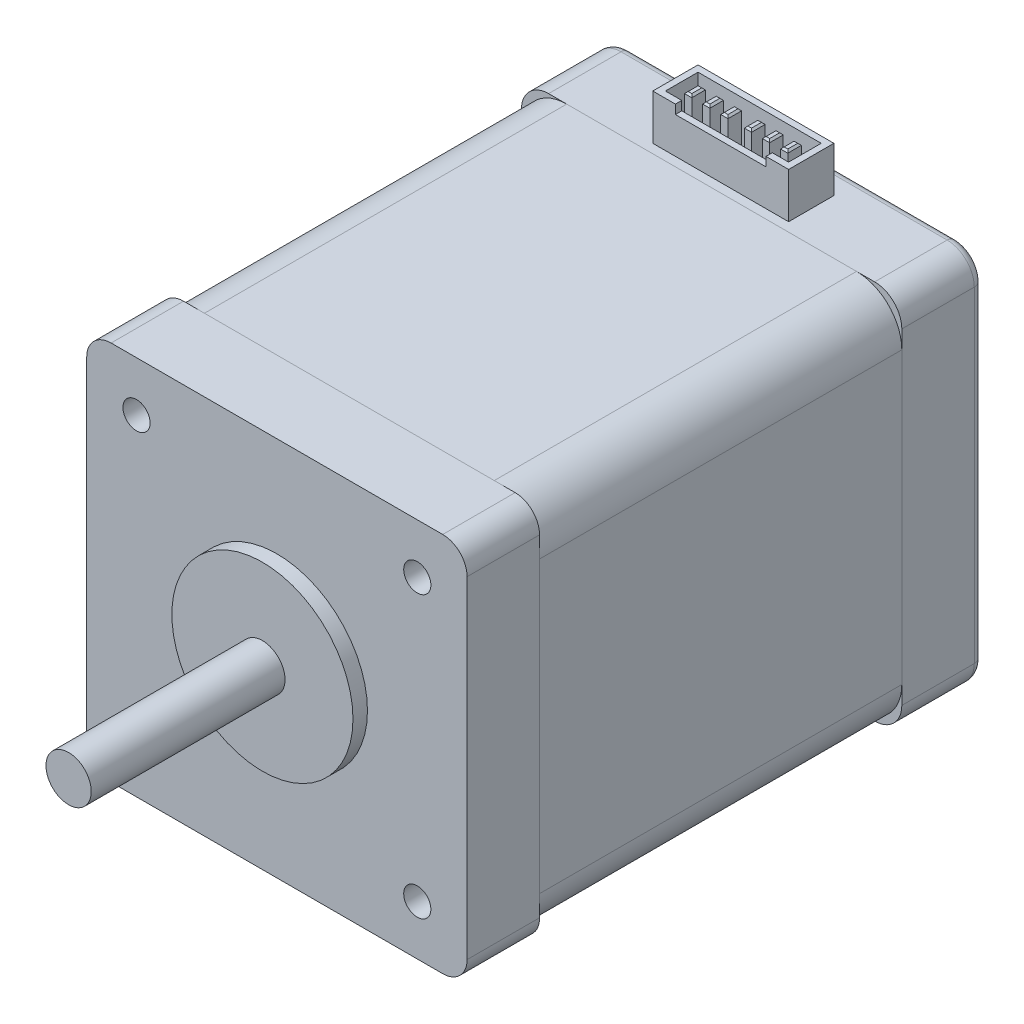
from build123d import *

# Parameters (mm, degrees)
SKETCH1_R           = 1.5
BOSS_EXTRUDE1_DEPTH = 8
SKETCH2_R           = 2.5
BOSS_EXTRUDE2_DEPTH = 23
SKETCH3_W           = 42
SKETCH3_H           = 42
BOSS_EXTRUDE3_DEPTH = 40
SKETCH4_W           = 42
SKETCH4_H           = 42
BOSS_EXTRUDE4_DEPTH = 9
FILLET1_R           = 3
FILLET3_R           = 5
SKETCH5_R           = 1.5
CUT_EXTRUDE1_DEPTH  = 81
SKETCH6_R           = 10
SKETCH6_R_2         = 2.5
BOSS_EXTRUDE5_DEPTH = 1.6
SKETCH7_W           = 0.8
SKETCH7_H           = 1.5
BOSS_EXTRUDE6_DEPTH = 5
CHAMFER1_SIZE       = 0.2
SKETCH8_W           = 10
SKETCH8_H           = 1
CUT_EXTRUDE2_DEPTH  = 0.7
FILLET5_R           = 1


with BuildPart() as part:
    # Sketch1 → Boss-Extrude1 (new body)
    with BuildSketch(Plane.XY):
        with BuildLine():
            Line((-18.307305591, -21), (18.307305591, -21))
            ThreePointArc((18.307305591, -21), (20.211328067, -20.211328067), (21, -18.307305591))
            Line((21, -18.307305591), (21, 18.307305591))
            ThreePointArc((21, 18.307305591), (20.211328067, 20.211328067), (18.307305591, 21))
            Line((18.307305591, 21), (-18.307305591, 21))
            ThreePointArc((-18.307305591, 21), (-20.211328067, 20.211328067), (-21, 18.307305591))
            Line((-21, 18.307305591), (-21, -18.307305591))
            ThreePointArc((-21, -18.307305591), (-20.211328067, -20.211328067), (-18.307305591, -21))
        make_face()
        with Locations((-15.5, 15.5)):
            Circle(SKETCH1_R, mode=Mode.SUBTRACT)
        with Locations((15.5, 15.5)):
            Circle(SKETCH1_R, mode=Mode.SUBTRACT)
        with Locations((15.5, -15.5)):
            Circle(SKETCH1_R, mode=Mode.SUBTRACT)
        with Locations((-15.5, -15.5)):
            Circle(SKETCH1_R, mode=Mode.SUBTRACT)
    extrude(amount=BOSS_EXTRUDE1_DEPTH)

    # Sketch2 → Boss-Extrude2 (add)
    with BuildSketch(Plane.XY.offset(8)):
        Circle(SKETCH2_R)
    extrude(amount=BOSS_EXTRUDE2_DEPTH)

    # Sketch6 → Boss-Extrude5 (add)
    with BuildSketch(Plane.XY.offset(8)):
        Circle(SKETCH6_R)
        Circle(SKETCH6_R_2, mode=Mode.SUBTRACT)
    extrude(amount=BOSS_EXTRUDE5_DEPTH)


with BuildPart() as body_2:
    # Sketch3 → Boss-Extrude3 (new body)
    with BuildSketch(Plane(origin=(0, 0, 0), x_dir=(-1, 0, 0), z_dir=(0, 0, -1))):
        Rectangle(SKETCH3_W, SKETCH3_H)
    extrude(amount=BOSS_EXTRUDE3_DEPTH)

    # Fillet3
    fillet3_edges = [body_2.edges().sort_by_distance(p)[0] for p in [
        (-21, -21, -20),
        (21, -21, -20),
        (21, 21, -20),
        (-21, 21, -20),
    ]]
    fillet(fillet3_edges, radius=FILLET3_R)


with BuildPart() as body_3:
    # Sketch4 → Boss-Extrude4 (new body)
    with BuildSketch(Plane(origin=(0, 0, -40), x_dir=(-1, 0, 0), z_dir=(0, 0, -1))):
        Rectangle(SKETCH4_W, SKETCH4_H)
    extrude(amount=BOSS_EXTRUDE4_DEPTH)

    # Fillet1
    fillet1_edges = [body_3.edges().sort_by_distance(p)[0] for p in [
        (21, -21, -44.5),
        (21, 21, -44.5),
        (-21, 21, -44.5),
        (-21, -21, -44.5),
    ]]
    fillet(fillet1_edges, radius=FILLET1_R)


with BuildPart() as cut_extrude1_tool:
    # Sketch5 → Cut-Extrude1 (new body, through all)
    with BuildSketch(Plane(origin=(0, 0, -49), x_dir=(-1, 0, 0), z_dir=(0, 0, -1))):
        with Locations((-15.5, 15.5)):
            Circle(SKETCH5_R)
        with Locations((-15.5, -15.5)):
            Circle(SKETCH5_R)
        with Locations((15.5, 15.5)):
            Circle(SKETCH5_R)
        with Locations((15.5, -15.5)):
            Circle(SKETCH5_R)
    extrude(amount=-CUT_EXTRUDE1_DEPTH)


with BuildPart() as body_2_1:
    add(body_2.part)

    # Cut-Extrude1: cut by cut_extrude1_tool
    add(cut_extrude1_tool.part, mode=Mode.SUBTRACT)


with BuildPart() as body_3_1:
    add(body_3.part)

    # Cut-Extrude1: cut by cut_extrude1_tool
    add(cut_extrude1_tool.part, mode=Mode.SUBTRACT)

    # Sketch7 → Boss-Extrude6 (add)
    with BuildSketch(Plane(origin=(0, 21, 0), x_dir=(1, 0, 0), z_dir=(0, 1, 0))):
        Polygon((7.5, 41), (7.5, 46), (0, 46), (-7.5, 46), (-7.5, 41), align=None)
        Polygon((6.8, 45.3), (0, 45.3), (-6.8, 45.3), (-6.8, 41.7), (0, 41.7), (6.8, 41.7), align=None, mode=Mode.SUBTRACT)
        with Locations((-5.3, 43.457)):
            Rectangle(SKETCH7_W, SKETCH7_H)
        with Locations((-3.3, 43.457)):
            Rectangle(SKETCH7_W, SKETCH7_H)
        with Locations((-1.3, 43.457)):
            Rectangle(SKETCH7_W, SKETCH7_H)
        with Locations((1.3, 43.457)):
            Rectangle(SKETCH7_W, SKETCH7_H)
        with Locations((3.3, 43.457)):
            Rectangle(SKETCH7_W, SKETCH7_H)
        with Locations((5.3, 43.457)):
            Rectangle(SKETCH7_W, SKETCH7_H)
    extrude(amount=BOSS_EXTRUDE6_DEPTH)

    # Chamfer1
    chamfer1_edges = [body_3_1.edges().sort_by_distance(p)[0] for p in [
        (-1.7, 26, -43.457),
        (-1.3, 26, -42.707),
        (-0.9, 26, -43.457),
        (-1.3, 26, -44.207),
        (1.3, 26, -44.207),
        (0.9, 26, -43.457),
        (1.3, 26, -42.707),
        (1.7, 26, -43.457),
        (3.3, 26, -44.207),
        (2.9, 26, -43.457),
        (3.3, 26, -42.707),
        (3.7, 26, -43.457),
        (5.3, 26, -44.207),
        (4.9, 26, -43.457),
        (5.3, 26, -42.707),
        (5.7, 26, -43.457),
        (-5.3, 26, -44.207),
        (-5.7, 26, -43.457),
        (-5.3, 26, -42.707),
        (-4.9, 26, -43.457),
        (-3.3, 26, -44.207),
        (-3.7, 26, -43.457),
        (-3.3, 26, -42.707),
        (-2.9, 26, -43.457),
    ]]
    chamfer(chamfer1_edges, length=CHAMFER1_SIZE)

    # Sketch8 → Cut-Extrude2 (cut)
    with BuildSketch(Plane.XY.offset(-41)):
        with Locations((0, 25.5)):
            Rectangle(SKETCH8_W, SKETCH8_H)
    extrude(amount=-CUT_EXTRUDE2_DEPTH, mode=Mode.SUBTRACT)

    # Fillet5
    fillet5_edges = [body_3_1.edges().sort_by_distance(p)[0] for p in [
        (-21, 0, -49),
        (0, -21, -49),
        (0, 21, -49),
        (21, 0, -49),
        (-20.121320344, 20.121320344, -49),
        (20.121320344, 20.121320344, -49),
        (20.121320344, -20.121320344, -49),
        (-20.121320344, -20.121320344, -49),
    ]]
    fillet(fillet5_edges, radius=FILLET5_R)


solid = Compound([part.part, body_2_1.part, body_3_1.part])
